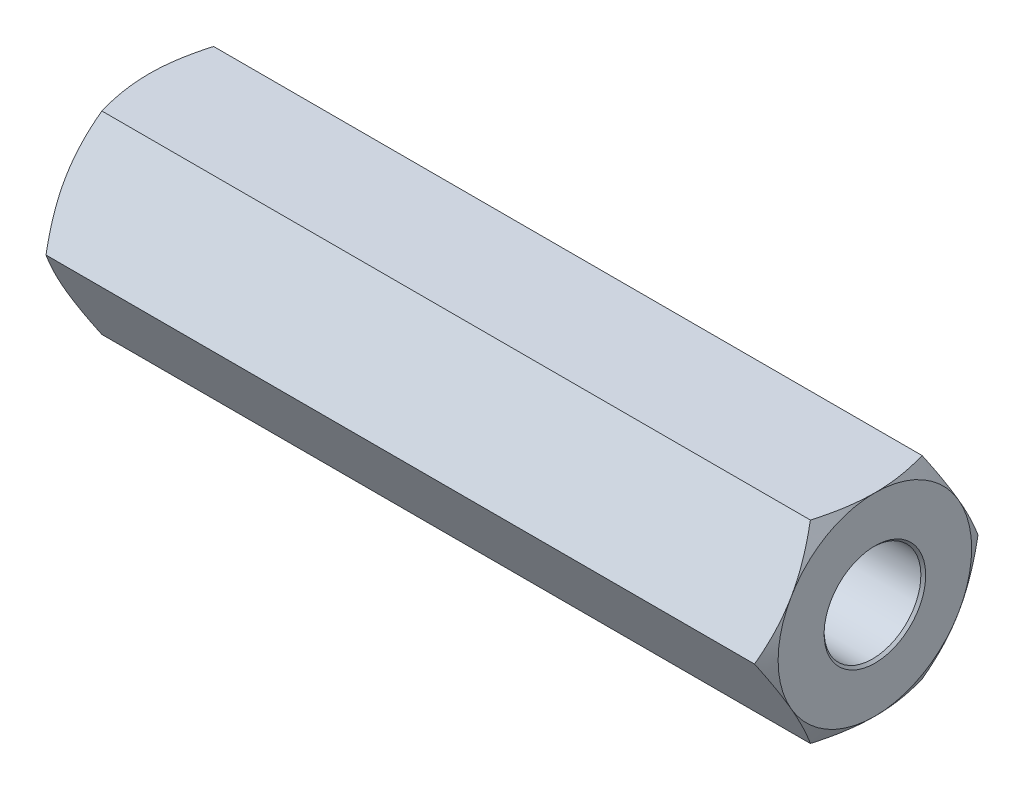
from build123d import *

# Parameters (mm, degrees)
BOSS_EXTRUDE1_DEPTH = 30
SKETCH4_OUTSIDE_W   = 125.104
SKETCH4_OUTSIDE_H   = 123.866
SKETCH4_OUTSIDE_R   = 4
CUT_EXTRUDE1_DEPTH  = 31
CUT_EXTRUDE1_TAPER  = 60
SKETCH5_OUTSIDE_W   = 125.104
SKETCH5_OUTSIDE_H   = 123.866
SKETCH5_OUTSIDE_R   = 4
CUT_EXTRUDE2_DEPTH  = 31
CUT_EXTRUDE2_TAPER  = 60


with BuildPart() as part:
    # Sketch2 → Boss-Extrude1 (new body)
    with BuildSketch(Plane(origin=(0, 0, 0), x_dir=(0, 0, -1), z_dir=(1, 0, 0))):
        Polygon((2.309401077, 4), (-2.309401077, 4), (-4.618802154, 0), (-2.309401077, -4), (2.309401077, -4), (4.618802154, 0), align=None)
    extrude(amount=BOSS_EXTRUDE1_DEPTH)

    # Sketch3 → Cut-Revolve1 (revolve, cut)
    with BuildSketch(Plane.XY):
        Polygon((0, 2.1), (0.1, 2), (11.1, 2), (11.1, 0), (0, 0), align=None)
        Polygon((30, 0), (18.9, 0), (18.9, 2), (29.9, 2), (30, 2.1), align=None)
    revolve(axis=Axis((0, 0, 0), (1, 0, 0)), mode=Mode.SUBTRACT)

    # Sketch4 outside → Cut-Extrude1 (cut, through all)
    with BuildSketch(Plane.ZY):
        Rectangle(SKETCH4_OUTSIDE_W, SKETCH4_OUTSIDE_H)
        Circle(SKETCH4_OUTSIDE_R, mode=Mode.SUBTRACT)
    extrude(amount=-CUT_EXTRUDE1_DEPTH, taper=CUT_EXTRUDE1_TAPER, mode=Mode.SUBTRACT)

    # Sketch5 outside → Cut-Extrude2 (cut, through all)
    with BuildSketch(Plane(origin=(30, 0, 0), x_dir=(0, 0, -1), z_dir=(1, 0, 0))):
        Rectangle(SKETCH5_OUTSIDE_W, SKETCH5_OUTSIDE_H)
        Circle(SKETCH5_OUTSIDE_R, mode=Mode.SUBTRACT)
    extrude(amount=-CUT_EXTRUDE2_DEPTH, taper=CUT_EXTRUDE2_TAPER, mode=Mode.SUBTRACT)


solid = part.part
